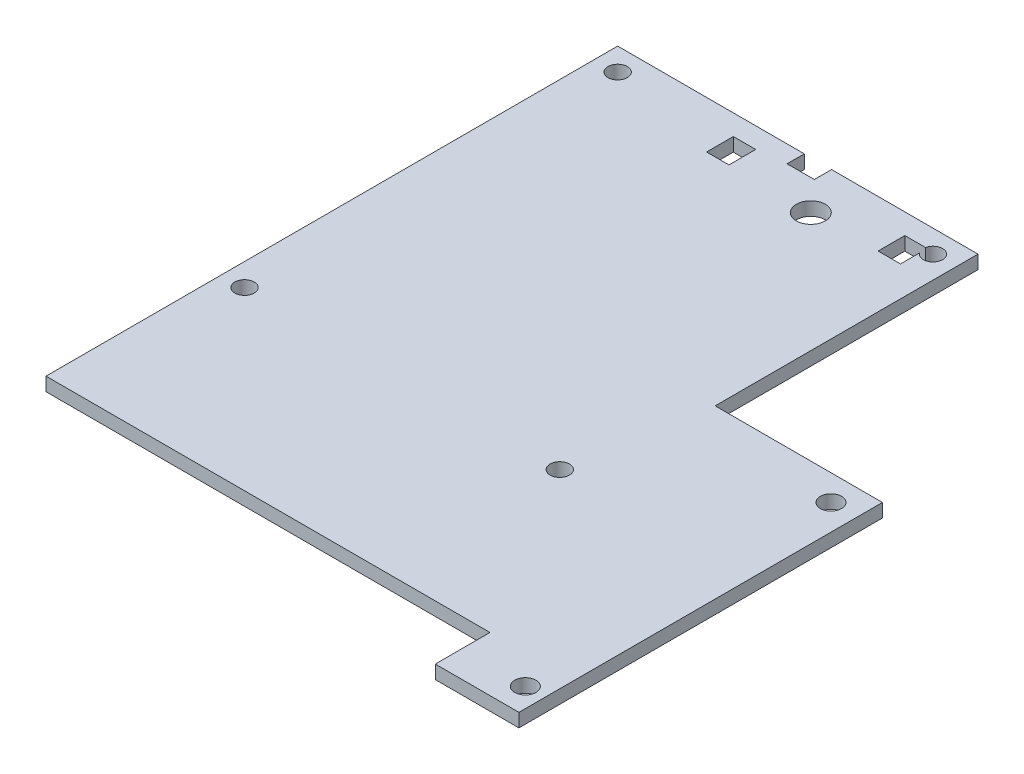
from build123d import *

# Parameters (mm, degrees)
SKETCH1_R           = 1.5
SKETCH1_R_2         = 1.65
SKETCH1_W           = 3.48
SKETCH1_H           = 4.16
SKETCH1_R_3         = 2.25
BOSS_EXTRUDE2_DEPTH = 2.1


with BuildPart() as part:
    # Sketch1 → Boss-Extrude2 (new body)
    with BuildSketch(Plane(origin=(0, 0, 0), x_dir=(1, 0, 0), z_dir=(0, 1, 0))):
        Polygon((0, 88.85), (0, 0), (69, 0), (69, -8.5), (82, -8.5), (82, 48), (56, 48), (56, 88.85), (33.24, 88.85), (33.24, 86.17), (29.01, 86.17), (29.01, 88.85), align=None)
        with Locations((3.5, 27.35)):
            Circle(SKETCH1_R, mode=Mode.SUBTRACT)
        with Locations((79, -4.5)):
            Circle(SKETCH1_R_2, mode=Mode.SUBTRACT)
        with Locations((52.5, 27.35)):
            Circle(SKETCH1_R, mode=Mode.SUBTRACT)
        with Locations((3.5, 85.35)):
            Circle(SKETCH1_R, mode=Mode.SUBTRACT)
        with Locations((22.9, 83.58)):
            Rectangle(SKETCH1_W, SKETCH1_H, mode=Mode.SUBTRACT)
        with Locations((37.42, 81.45)):
            Circle(SKETCH1_R_3, mode=Mode.SUBTRACT)
        with Locations((78, 44)):
            Circle(SKETCH1_R_2, mode=Mode.SUBTRACT)
        with BuildLine():
            Line((51.3, 84.45), (51.3, 81.5))
            Line((51.3, 81.5), (47.82, 81.5))
            Line((47.82, 81.5), (47.82, 85.66))
            Line((47.82, 85.66), (51.032382884, 85.66))
            ThreePointArc((51.032382884, 85.66), (52.655843392, 86.841882313), (54, 85.35))
            ThreePointArc((54, 85.35), (52.974341649, 83.926975053), (51.3, 84.45))
        make_face(mode=Mode.SUBTRACT)
    extrude(amount=-BOSS_EXTRUDE2_DEPTH)


solid = part.part
